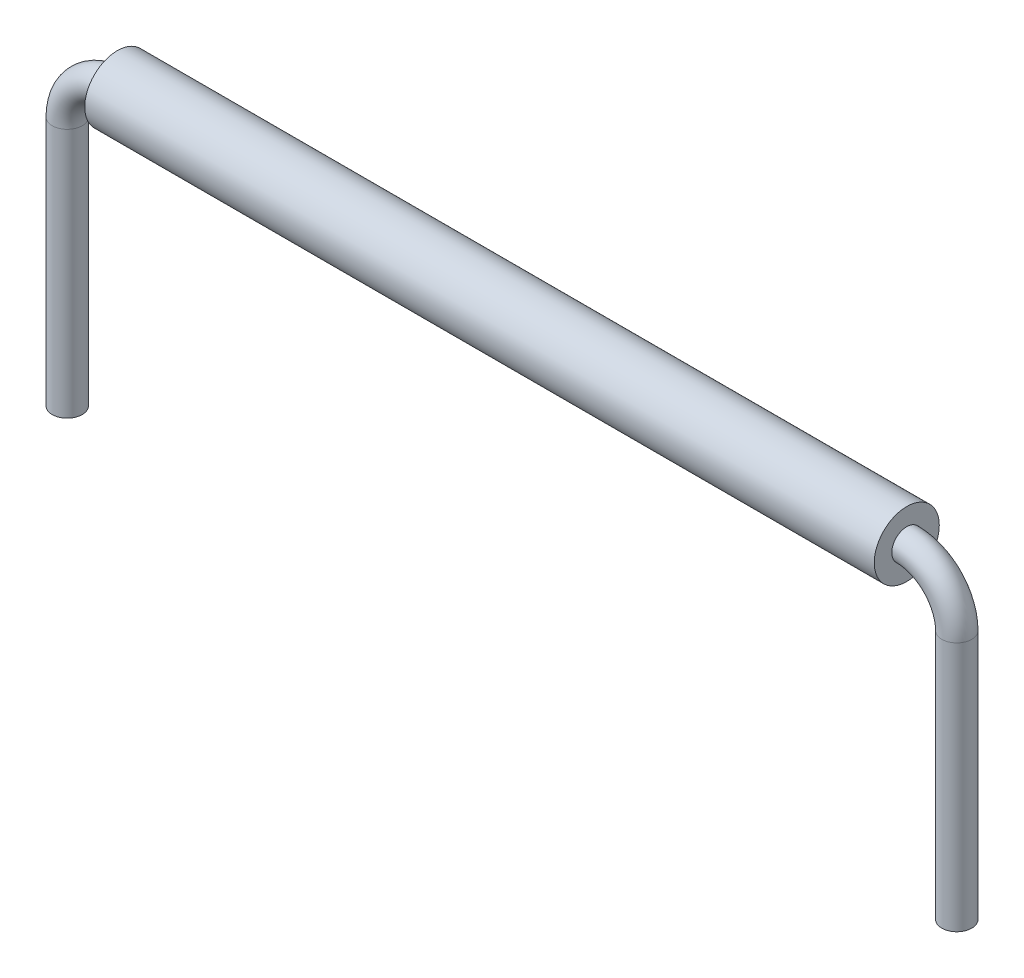
from build123d import *

# Parameters (mm, degrees)
SKETCH2_R                = 0.3
SKETCH3_R                = 0.65
SKETCH3_R_2              = 0.3
BOSS_EXTRUDE1_DEPTH      = 7.89
BOSS_EXTRUDE1_DEPTH_BACK = 7.89


with BuildPart() as part:
    # Sweep1: sweep along a path in Sketch1
    with BuildLine(Plane.XY) as sweep1_path:
        Line((-8.89, -6), (-8.89, -1))
        ThreePointArc((-8.89, -1), (-8.597106781, -0.292893219), (-7.89, 0))
        Line((-7.89, 0), (7.89, 0))
        ThreePointArc((7.89, 0), (8.597106781, -0.292893219), (8.89, -1))
        Line((8.89, -1), (8.89, -6))
    # Sketch2 → Sweep1 (sweep)
    with BuildSketch(Plane(origin=(0, 0, 0), x_dir=(0, 0, -1), z_dir=(1, 0, 0))):
        Circle(SKETCH2_R)
    sweep(path=sweep1_path.line)


with BuildPart() as body_2:
    # Sketch3 → Boss-Extrude1 (new body, two sides)
    with BuildSketch(Plane(origin=(0, 0, 0), x_dir=(0, 0, -1), z_dir=(1, 0, 0))) as boss_extrude1_sk:
        Circle(SKETCH3_R)
        Circle(SKETCH3_R_2, mode=Mode.SUBTRACT)
    extrude(amount=BOSS_EXTRUDE1_DEPTH)
    extrude(boss_extrude1_sk.sketch, amount=-BOSS_EXTRUDE1_DEPTH_BACK)


solid = Compound([part.part, body_2.part])
